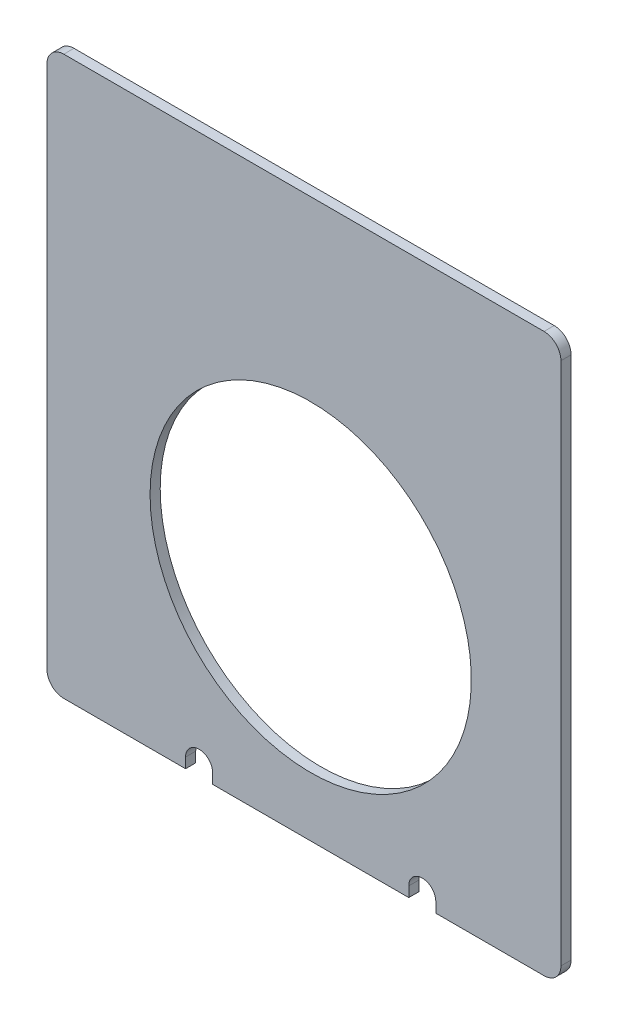
from build123d import *

# Parameters (mm, degrees)
ESQUISSE1_W             = 152
ESQUISSE1_H             = 165
BOSS_EXTRU_1_DEPTH      = 3
CONG_1_R                = 5
ESQUISSE2_R             = 47.5
ENL_V_MAT_EXTRU_1_DEPTH = 3
ENL_V_MAT_EXTRU_2_DEPTH = 3


with BuildPart() as part:
    # Esquisse1 → Boss.-Extru.1 (new body)
    with BuildSketch(Plane.XY):
        with Locations((-76, 82.5)):
            Rectangle(ESQUISSE1_W, ESQUISSE1_H)
    extrude(amount=BOSS_EXTRU_1_DEPTH)

    # Congé1
    cong_1_edges = [part.edges().sort_by_distance(p)[0] for p in [
        (0, 0, 1.5),
        (-152, 0, 1.5),
        (-152, 165, 1.5),
        (0, 165, 1.5),
    ]]
    fillet(cong_1_edges, radius=CONG_1_R)

    # Esquisse2 → Enlèv. mat.-Extru.1 (cut)
    with BuildSketch(Plane(origin=(0, 0, 0), x_dir=(-1, 0, 0), z_dir=(0, 0, -1))):
        with Locations((74, 65)):
            Circle(ESQUISSE2_R)
    extrude(amount=-ENL_V_MAT_EXTRU_1_DEPTH, mode=Mode.SUBTRACT)

    # Esquisse3 → Enlèv. mat.-Extru.2 (cut)
    with BuildSketch(Plane(origin=(0, 0, 0), x_dir=(-1, 0, 0), z_dir=(0, 0, -1))):
        with BuildLine():
            Line((37, -3), (37, 3))
            ThreePointArc((37, 3), (41, 7), (45, 3))
            Line((45, 3), (45, -3))
            ThreePointArc((45, -3), (41, -7), (37, -3))
        make_face()
        with BuildLine():
            Line((103, -3), (103, 3))
            ThreePointArc((103, 3), (107, 7), (111, 3))
            Line((111, 3), (111, -3))
            ThreePointArc((111, -3), (107, -7), (103, -3))
        make_face()
    extrude(amount=-ENL_V_MAT_EXTRU_2_DEPTH, mode=Mode.SUBTRACT)


solid = part.part
